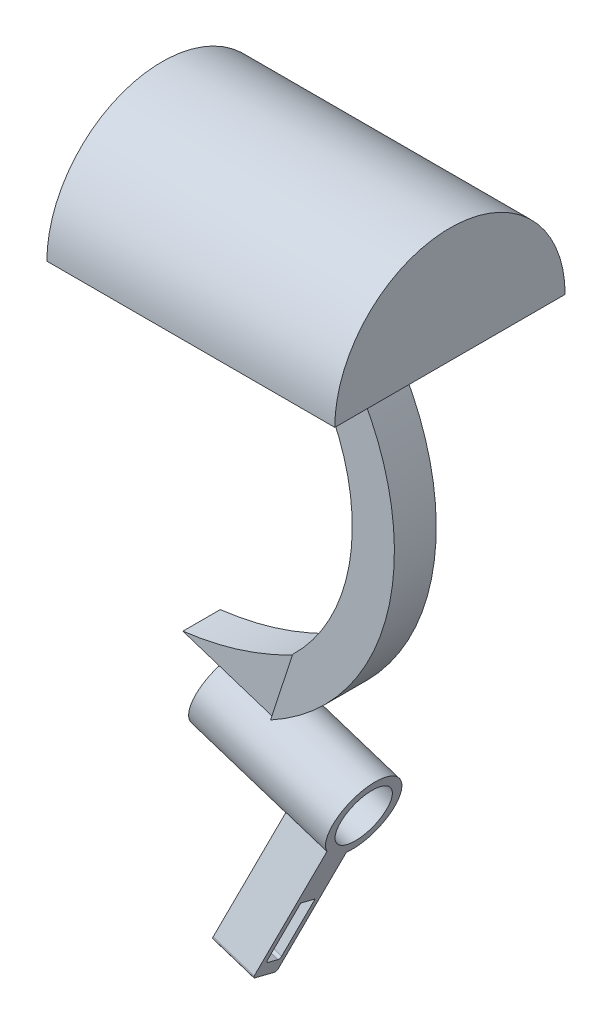
from build123d import *

# Parameters (mm, degrees)
SKETCH1_W               = 25.4
SKETCH1_H               = 10.16
REVOLVE1_ANGLE          = 180
SKETCH4_W               = 6.29000012
SKETCH4_H               = 3.69
SKETCH6_W               = 3.294985449
SKETCH6_H               = 5.974962046
BOSS_EXTRUDE1_DEPTH     = 5.08
SKETCH7_R               = 3.22
BOSS_EXTRUDE7_DEPTH     = 12.7
SKETCH9_W               = 3.294985449
SKETCH9_H               = 5.974962046
BOSS_EXTRUDE8_DEPTH     = 3.302
CUT_EXTRUDE1_DEPTH      = 3.302
CUT_EXTRUDE1_DEPTH_BACK = 3.302
SKETCH11_R              = 2.375
CUT_EXTRUDE2_DEPTH      = 2.54
CUT_EXTRUDE2_DEPTH_BACK = 12.446
BOSS_EXTRUDE11_DEPTH    = 3.81
SKETCH14_R              = 2.420907349
CUT_EXTRUDE3_DEPTH      = 22.606


with BuildPart() as part:
    # Sketch1 → Revolve1 (revolve)
    with BuildSketch(Plane(origin=(0, 0, 0), x_dir=(1, 0, 0), z_dir=(0, 1, 0))):
        with Locations((12.7, 5.451011236)):
            Rectangle(SKETCH1_W, SKETCH1_H)
    revolve(axis=Axis((0, 0, -0.371011236), (1, 0, 0)), revolution_arc=REVOLVE1_ANGLE)

    # Sweep1: sweep along a path in Sketch5
    with BuildLine(Plane.XY) as sweep1_path:
        ThreePointArc((12.7, 0), (20.315428689, -15.331843414), (12.392600359, -30.5071183))
    # Sketch4 → Sweep1 (sweep)
    with BuildSketch(Plane(origin=(0, 0, 0), x_dir=(1, 0, 0), z_dir=(0, 1, 0))):
        with Locations((12.7, 0.371011236)):
            Rectangle(SKETCH4_W, SKETCH4_H)
    sweep(path=sweep1_path.line)

    # Sketch6 → Boss-Extrude1 (add)
    with BuildSketch(Plane(origin=(20.164340987, -6.538110874, 0), x_dir=(0, 0, 1), z_dir=(-0.95124601, 0.308433183, 0))):
        with Locations((-0.361104817, -25.204906835)):
            Rectangle(SKETCH6_W, SKETCH6_H)
    extrude(amount=BOSS_EXTRUDE1_DEPTH)

    # Sketch7 → Boss-Extrude7 (add)
    with BuildSketch(Plane(origin=(15.332011256, -4.971270302, 0), x_dir=(0, 0, 1), z_dir=(-0.95124601, 0.308433183, 0))):
        with Locations((-0.361104816, -31.160979548)):
            Circle(SKETCH7_R)
    extrude(amount=-BOSS_EXTRUDE7_DEPTH)

    # Sketch9 → Boss-Extrude8 (add)
    with BuildSketch(Plane(origin=(15.332011256, -4.971270302, 0), x_dir=(0, 0, 1), z_dir=(-0.95124601, 0.308433183, 0))):
        with Locations((-0.361104817, -25.204906835)):
            Rectangle(SKETCH9_W, SKETCH9_H)
    extrude(amount=BOSS_EXTRUDE8_DEPTH)

    # Sketch10 → Cut-Extrude1 (cut, two sides)
    with BuildSketch(Plane.XY) as cut_extrude1_sk:
        with BuildLine():
            Line((3.495528998, -30.770720391), (5.338405562, -25.087061585))
            Line((5.338405562, -25.087061585), (13.311749617, -27.672348528))
            add(Edge.make_bspline(
                [(13.311749617, -27.672348528), (8.683653097, -30.129373505), (3.495528998, -30.770720391)],
                knots=[0, 0, 0, 1, 1, 1], degree=2))
        make_face()
    extrude(amount=CUT_EXTRUDE1_DEPTH, mode=Mode.SUBTRACT)
    extrude(cut_extrude1_sk.sketch, amount=-CUT_EXTRUDE1_DEPTH_BACK, mode=Mode.SUBTRACT)

    # Sketch11 → Cut-Extrude2 (cut, two sides)
    with BuildSketch(Plane(origin=(27.412835582, -8.888371731, 0), x_dir=(0, 0, -1), z_dir=(0.95124601, -0.308433183, 0))) as cut_extrude2_sk:
        with Locations((0.39169909, -31.12675273)):
            Circle(SKETCH11_R)
    extrude(amount=CUT_EXTRUDE2_DEPTH, mode=Mode.SUBTRACT)
    extrude(cut_extrude2_sk.sketch, amount=-CUT_EXTRUDE2_DEPTH_BACK, mode=Mode.SUBTRACT)

    # Sketch13 → Boss-Extrude11 (add)
    with BuildSketch(Plane(origin=(27.412835582, -8.888371731, 0), x_dir=(0, 0, -1), z_dir=(0.95124601, -0.308433183, 0))):
        Polygon((-2.207938212, -40.151875097), (-0.189276492, -34.333593678), (-2.341873796, -32.910924296), (-4.569820403, -39.332416424), (-4.097443964, -39.496308159), (-3.315450943, -37.242411221), (-1.898321628, -37.734086425), (-2.68031465, -39.987983362), align=None)
        with BuildLine():
            Line((-3.374575741, -43.514412461), (-2.207938212, -40.151875097))
            Line((-2.207938212, -40.151875097), (-2.68031465, -39.987983362))
            Line((-2.68031465, -39.987983362), (-3.462307672, -42.241880299))
            ThreePointArc((-3.462307672, -42.241880299), (-3.5785484, -42.37264764), (-3.75320948, -42.382919506))
            Line((-3.75320948, -42.382919506), (-4.73839778, -42.041106905))
            ThreePointArc((-4.73839778, -42.041106905), (-4.86916512, -41.924866176), (-4.879436986, -41.750205096))
            Line((-4.879436986, -41.750205096), (-4.097443964, -39.496308159))
            Line((-4.097443964, -39.496308159), (-4.569820403, -39.332416424))
            Line((-4.569820403, -39.332416424), (-5.736457932, -42.694953789))
            ThreePointArc((-5.736457932, -42.694953789), (-5.726186066, -42.869614869), (-5.595418726, -42.985855597))
            Line((-5.595418726, -42.985855597), (-3.66547755, -43.655451668))
            ThreePointArc((-3.66547755, -43.655451668), (-3.490816469, -43.645179802), (-3.374575741, -43.514412461))
        make_face()
    extrude(amount=-BOSS_EXTRUDE11_DEPTH)

    # Sketch14 → Cut-Extrude3 (cut)
    with BuildSketch(Plane(origin=(27.412835582, -8.888371731, 0), x_dir=(0, 0, -1), z_dir=(0.95124601, -0.308433183, 0))):
        with Locations((0.361104816, -31.160979548)):
            Circle(SKETCH14_R)
    extrude(amount=-CUT_EXTRUDE3_DEPTH, mode=Mode.SUBTRACT)


solid = part.part
